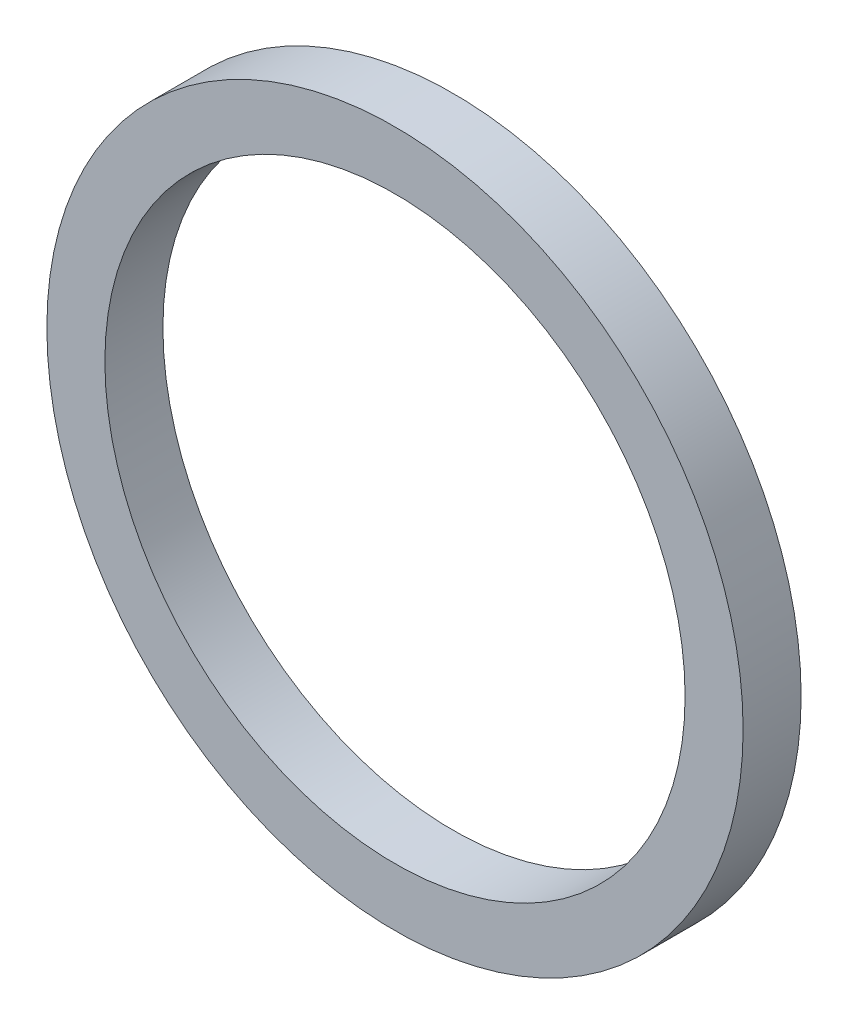
from build123d import *

# Parameters (mm, degrees)
SKETCH1_R           = 15.24
BOSS_EXTRUDE1_DEPTH = 2.54
SKETCH2_R           = 12.7
CUT_EXTRUDE1_DEPTH  = 3.54


with BuildPart() as part:
    # Sketch1 → Boss-Extrude1 (new body)
    with BuildSketch(Plane.XY):
        Circle(SKETCH1_R)
    extrude(amount=BOSS_EXTRUDE1_DEPTH)

    # Sketch2 → Cut-Extrude1 (cut, through all)
    with BuildSketch(Plane.XY.offset(2.54)):
        Circle(SKETCH2_R)
    extrude(amount=-CUT_EXTRUDE1_DEPTH, mode=Mode.SUBTRACT)


solid = part.part
